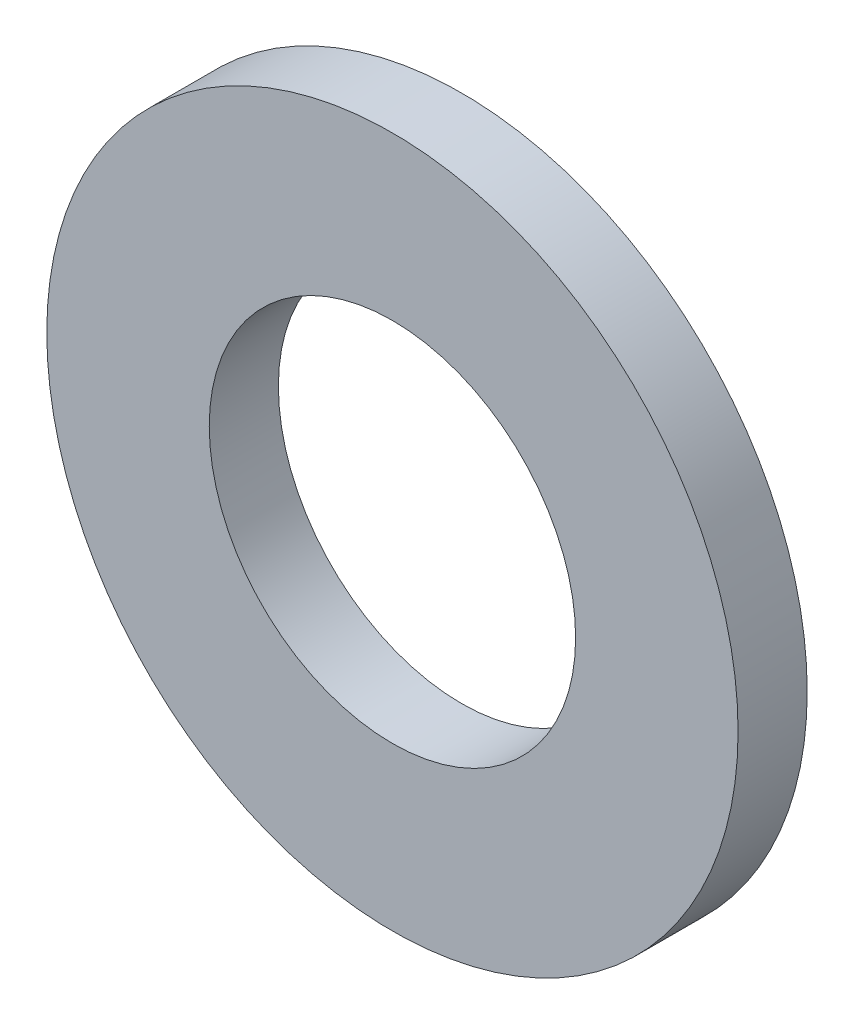
from build123d import *

# Parameters (mm, degrees)
SKETCH1_R      = 5
SKETCH1_R_2    = 2.65
EXTRUDE1_DEPTH = 1


with BuildPart() as part:
    # Sketch1 → Extrude1 (new body)
    with BuildSketch(Plane.XY):
        Circle(SKETCH1_R)
        Circle(SKETCH1_R_2, mode=Mode.SUBTRACT)
    extrude(amount=-EXTRUDE1_DEPTH)


solid = part.part
